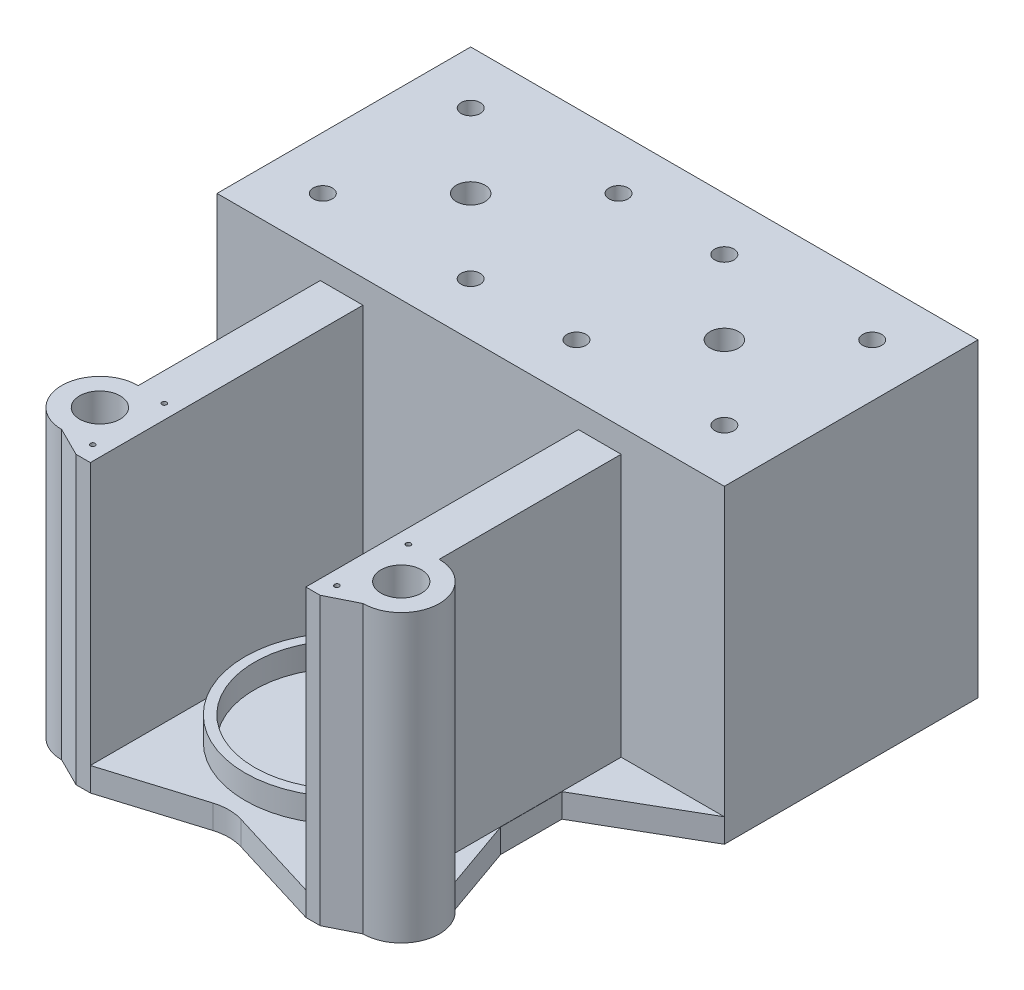
from build123d import *

# Parameters (mm, degrees)
SKETCH1_R                       = 21.15
BOSS_EXTRUDE1_DEPTH             = 5
SKETCH2_R                       = 21.15
SKETCH2_R_2                     = 19.15
BOSS_EXTRUDE2_DEPTH             = 10
SKETCH3_R                       = 8
SKETCH3_W                       = 53.18
SKETCH3_H                       = 53.18
SKETCH3_W_2                     = 43.18
SKETCH3_H_2                     = 43.18
SKETCH3_R_2                     = 21.15
BOSS_EXTRUDE4_DEPTH             = 5
SKETCH4_W                       = 106.36
SKETCH4_H                       = 53.18
SKETCH4_W_2                     = 43.18
SKETCH4_H_2                     = 43.18
SKETCH4_R                       = 0.5
SKETCH4_R_2                     = 4.25
BOSS_EXTRUDE5_DEPTH             = 55
BOSS_EXTRUDE5_DIRECTION_2_REACH = 97.637
SKETCH5_R                       = 1.566567696
SKETCH5_R_2                     = 1.356312868
SKETCH5_R_3                     = 1.387107712
SKETCH5_R_4                     = 1.945059914
BOSS_EXTRUDE6_DEPTH             = 50
SKETCH6_W                       = 106.36
SKETCH6_H                       = 53.18
SKETCH6_R                       = 3
SKETCH6_R_2                     = 2
BOSS_EXTRUDE7_DEPTH             = 5
SKETCH7_W                       = 22
SKETCH7_H                       = 23
CUT_EXTRUDE1_DEPTH              = 5
BOSS_EXTRUDE8_DEPTH             = 60
BOSS_EXTRUDE9_DEPTH             = 5


with BuildPart() as part:
    # Sketch1 → Boss-Extrude1 (new body)
    with BuildSketch(Plane(origin=(0, 0, 0), x_dir=(1, 0, 0), z_dir=(0, 1, 0))):
        with Locations(Location((0, 0, 0), (0, 0, 270))):
            Circle(SKETCH1_R)
    extrude(amount=BOSS_EXTRUDE1_DEPTH)

    # Sketch2 → Boss-Extrude2 (add)
    with BuildSketch(Plane(origin=(0, 0, 0), x_dir=(1, 0, 0), z_dir=(0, 1, 0))):
        with Locations(Location((0, 0, 0), (0, 0, 270))):
            Circle(SKETCH2_R)
        with Locations(Location((0, 0, 0), (0, 0, 270))):
            Circle(SKETCH2_R_2, mode=Mode.SUBTRACT)
    extrude(amount=BOSS_EXTRUDE2_DEPTH)

    # Sketch3 → Boss-Extrude4 (add)
    with BuildSketch(Plane(origin=(0, 0, 0), x_dir=(1, 0, 0), z_dir=(0, 1, 0))):
        with Locations((31.59, -20)):
            Circle(SKETCH3_R)
        with Locations((-31.59, -20)):
            Circle(SKETCH3_R)
        with Locations((26.59, 52.74)):
            Rectangle(SKETCH3_W, SKETCH3_H)
        with Locations((26.59, 52.74)):
            Rectangle(SKETCH3_W_2, SKETCH3_H_2, mode=Mode.SUBTRACT)
        with Locations((-26.59, 52.74)):
            Rectangle(SKETCH3_W, SKETCH3_H)
        with Locations((-26.59, 52.74)):
            Rectangle(SKETCH3_W_2, SKETCH3_H_2, mode=Mode.SUBTRACT)
        with BuildLine():
            Line((53.18, 26.15), (0, 26.15))
            Line((0, 26.15), (-53.18, 26.15))
            Line((-53.18, 26.15), (-31.59, 13.685007688))
            Line((-31.59, 13.685007688), (-31.59, 0.832649627))
            Line((-31.59, 0.832649627), (-36.793594364, -13.923602573))
            ThreePointArc((-36.793594364, -13.923602573), (-28.245508627, -12.732649901), (-23.59, -20))
            ThreePointArc((-23.59, -20), (-24.322649901, -23.344491373), (-26.386405636, -26.076397427))
            Line((-26.386405636, -26.076397427), (0, -21.15))
            Line((0, -21.15), (26.386405636, -26.076397427))
            ThreePointArc((26.386405636, -26.076397427), (25.513602573, -14.796405636), (36.793594364, -13.923602573))
            Line((36.793594364, -13.923602573), (31.59, 0.832649627))
            Line((31.59, 0.832649627), (31.59, 13.685007688))
            Line((31.59, 13.685007688), (53.18, 26.15))
        make_face()
        with BuildLine():
            ThreePointArc((21.15, 0), (14.955308422, -14.955308422), (0, -21.15))
            ThreePointArc((0, -21.15), (-14.955308422, 14.955308422), (21.15, 0))
        make_face(mode=Mode.SUBTRACT)
        with Locations(Location((0, 0, 0), (0, 0, 270))):
            Circle(SKETCH3_R_2)
    extrude(amount=BOSS_EXTRUDE4_DEPTH)

    # Sketch4 → Boss-Extrude5 (add)
    with BuildSketch(Plane(origin=(0, 5, 0), x_dir=(1, 0, 0), z_dir=(0, 1, 0))):
        with Locations((0, 52.74)):
            Rectangle(SKETCH4_W, SKETCH4_H)
        with Locations((-26.59, 52.74)):
            Rectangle(SKETCH4_W_2, SKETCH4_H_2, mode=Mode.SUBTRACT)
        with Locations((26.59, 52.74)):
            Rectangle(SKETCH4_W_2, SKETCH4_H_2, mode=Mode.SUBTRACT)
        with BuildLine():
            ThreePointArc((-31.59, -12), (-39.59, -20), (-31.59, -28))
            Line((-31.59, -28), (-25.59, -31))
            Line((-25.59, -31), (-22.59, -31))
            Line((-22.59, -31), (-22.59, -9))
            Line((-22.59, -9), (-25.59, -9))
            Line((-25.59, -9), (-31.59, -12))
        make_face()
        with Locations(Location((-25.59, -27.5, 0), (0, 0, 270))):
            Circle(SKETCH4_R, mode=Mode.SUBTRACT)
        with Locations(Location((-31.59, -20, 0), (0, 0, 270))):
            Circle(SKETCH4_R_2, mode=Mode.SUBTRACT)
        with Locations(Location((-25.59, -12.5, 0), (0, 0, 270))):
            Circle(SKETCH4_R, mode=Mode.SUBTRACT)
        with BuildLine():
            Line((31.59, -12), (25.59, -9))
            Line((25.59, -9), (22.59, -9))
            Line((22.59, -9), (22.59, -31))
            Line((22.59, -31), (25.59, -31))
            Line((25.59, -31), (31.59, -28))
            ThreePointArc((31.59, -28), (39.59, -20), (31.59, -12))
        make_face()
        with Locations(Location((25.59, -27.5, 0), (0, 0, 270))):
            Circle(SKETCH4_R, mode=Mode.SUBTRACT)
        with Locations(Location((25.59, -12.5, 0), (0, 0, 270))):
            Circle(SKETCH4_R, mode=Mode.SUBTRACT)
        with Locations(Location((31.59, -20, 0), (0, 0, 270))):
            Circle(SKETCH4_R_2, mode=Mode.SUBTRACT)
    extrude(amount=BOSS_EXTRUDE5_DEPTH)

    # Boss-Extrude5 direction 2: up to this face of the body (flat: up to its plane)
    boss_extrude5_direction_2_end = Plane(part.part.faces().sort_by_distance((0, 0, -18.773899986))[0])
    # Sketch4 → Boss-Extrude5 direction 2 (add, up to the picked face)
    with BuildSketch(Plane(origin=(0, 5, 0), x_dir=(1, 0, 0), z_dir=(0, 1, 0)), mode=Mode.PRIVATE) as boss_extrude5_direction_2_sk1:
        with Locations((0, 52.74)):
            Rectangle(SKETCH4_W, SKETCH4_H)
        with Locations((-26.59, 52.74)):
            Rectangle(SKETCH4_W_2, SKETCH4_H_2, mode=Mode.SUBTRACT)
        with Locations((26.59, 52.74)):
            Rectangle(SKETCH4_W_2, SKETCH4_H_2, mode=Mode.SUBTRACT)
    boss_extrude5_direction_2_tool1 = split(extrude(boss_extrude5_direction_2_sk1.sketch, amount=-BOSS_EXTRUDE5_DIRECTION_2_REACH, mode=Mode.PRIVATE), bisect_by=boss_extrude5_direction_2_end, keep=Keep.BOTH, mode=Mode.PRIVATE)
    # Sketch4 → Boss-Extrude5 direction 2 (add, up to the picked face)
    with BuildSketch(Plane(origin=(0, 5, 0), x_dir=(1, 0, 0), z_dir=(0, 1, 0)), mode=Mode.PRIVATE) as boss_extrude5_direction_2_sk2:
        with BuildLine():
            ThreePointArc((-31.59, -12), (-39.59, -20), (-31.59, -28))
            Line((-31.59, -28), (-25.59, -31))
            Line((-25.59, -31), (-22.59, -31))
            Line((-22.59, -31), (-22.59, -9))
            Line((-22.59, -9), (-25.59, -9))
            Line((-25.59, -9), (-31.59, -12))
        make_face()
        with Locations(Location((-25.59, -27.5, 0), (0, 0, 270))):
            Circle(SKETCH4_R, mode=Mode.SUBTRACT)
        with Locations(Location((-31.59, -20, 0), (0, 0, 270))):
            Circle(SKETCH4_R_2, mode=Mode.SUBTRACT)
        with Locations(Location((-25.59, -12.5, 0), (0, 0, 270))):
            Circle(SKETCH4_R, mode=Mode.SUBTRACT)
    boss_extrude5_direction_2_tool2 = split(extrude(boss_extrude5_direction_2_sk2.sketch, amount=-BOSS_EXTRUDE5_DIRECTION_2_REACH, mode=Mode.PRIVATE), bisect_by=boss_extrude5_direction_2_end, keep=Keep.BOTH, mode=Mode.PRIVATE)
    # Sketch4 → Boss-Extrude5 direction 2 (add, up to the picked face)
    with BuildSketch(Plane(origin=(0, 5, 0), x_dir=(1, 0, 0), z_dir=(0, 1, 0)), mode=Mode.PRIVATE) as boss_extrude5_direction_2_sk3:
        with BuildLine():
            Line((31.59, -12), (25.59, -9))
            Line((25.59, -9), (22.59, -9))
            Line((22.59, -9), (22.59, -31))
            Line((22.59, -31), (25.59, -31))
            Line((25.59, -31), (31.59, -28))
            ThreePointArc((31.59, -28), (39.59, -20), (31.59, -12))
        make_face()
        with Locations(Location((25.59, -27.5, 0), (0, 0, 270))):
            Circle(SKETCH4_R, mode=Mode.SUBTRACT)
        with Locations(Location((25.59, -12.5, 0), (0, 0, 270))):
            Circle(SKETCH4_R, mode=Mode.SUBTRACT)
        with Locations(Location((31.59, -20, 0), (0, 0, 270))):
            Circle(SKETCH4_R_2, mode=Mode.SUBTRACT)
    boss_extrude5_direction_2_tool3 = split(extrude(boss_extrude5_direction_2_sk3.sketch, amount=-BOSS_EXTRUDE5_DIRECTION_2_REACH, mode=Mode.PRIVATE), bisect_by=boss_extrude5_direction_2_end, keep=Keep.BOTH, mode=Mode.PRIVATE)
    add(boss_extrude5_direction_2_tool1.solids().sort_by(Axis((0, 5, -52.74), (0, -1, 0)))[0])
    add(boss_extrude5_direction_2_tool2.solids().sort_by(Axis((-39.311971, 5, 20), (0, -1, 0)))[0])
    add(boss_extrude5_direction_2_tool3.solids().sort_by(Axis((28.465662, 5, 10.748676), (0, -1, 0)))[0])

    # Sketch5 → Boss-Extrude6 (add)
    with BuildSketch(Plane(origin=(0, 5, 0), x_dir=(1, 0, 0), z_dir=(0, 1, 0))):
        with Locations((-25.59, -27.5)):
            Circle(SKETCH5_R)
        with Locations((-25.59, -12.5)):
            Circle(SKETCH5_R_2)
        with Locations((25.59, -12.5)):
            Circle(SKETCH5_R_3)
        with Locations((25.59, -23.409830044)):
            Circle(SKETCH5_R_4)
    extrude(amount=BOSS_EXTRUDE6_DEPTH)

    # Sketch6 → Boss-Extrude7 (add)
    with BuildSketch(Plane(origin=(0, 60, 0), x_dir=(1, 0, 0), z_dir=(0, 1, 0))):
        with Locations((0, 52.74)):
            Rectangle(SKETCH6_W, SKETCH6_H)
        with Locations(Location((-26.59, 52.74, 0), (0, 0, 270))):
            Circle(SKETCH6_R, mode=Mode.SUBTRACT)
        with Locations(Location((26.59, 52.74, 0), (0, 0, 270))):
            Circle(SKETCH6_R, mode=Mode.SUBTRACT)
        with Locations(Location((-42.09, 68.24, 0), (0, 0, 270))):
            Circle(SKETCH6_R_2, mode=Mode.SUBTRACT)
        with Locations(Location((-11.09, 68.24, 0), (0, 0, 270))):
            Circle(SKETCH6_R_2, mode=Mode.SUBTRACT)
        with Locations(Location((-11.09, 37.24, 0), (0, 0, 270))):
            Circle(SKETCH6_R_2, mode=Mode.SUBTRACT)
        with Locations(Location((-42.09, 37.24, 0), (0, 0, 270))):
            Circle(SKETCH6_R_2, mode=Mode.SUBTRACT)
        with Locations(Location((11.09, 68.24, 0), (0, 0, 90))):
            Circle(SKETCH6_R_2, mode=Mode.SUBTRACT)
        with Locations(Location((11.09, 37.24, 0), (0, 0, 90))):
            Circle(SKETCH6_R_2, mode=Mode.SUBTRACT)
        with Locations(Location((42.09, 37.24, 0), (0, 0, 90))):
            Circle(SKETCH6_R_2, mode=Mode.SUBTRACT)
        with Locations(Location((42.09, 68.24, 0), (0, 0, 90))):
            Circle(SKETCH6_R_2, mode=Mode.SUBTRACT)
    extrude(amount=BOSS_EXTRUDE7_DEPTH)

    # Sketch7 → Cut-Extrude1 (cut)
    with BuildSketch(Plane(origin=(0, 0, -79.33), x_dir=(-1, 0, 0), z_dir=(0, 0, -1))):
        with Locations((-28.18, 11.5)):
            Rectangle(SKETCH7_W, SKETCH7_H)
        with Locations((28.18, 11.5)):
            Rectangle(SKETCH7_W, SKETCH7_H)
    extrude(amount=-CUT_EXTRUDE1_DEPTH, mode=Mode.SUBTRACT)

    # Sketch8 → Boss-Extrude8 (add)
    with BuildSketch(Plane(origin=(0, 60, 0), x_dir=(1, 0, 0), z_dir=(0, 1, 0))):
        Polygon((-31.542803854, -13.152023689), (-31.542803854, 26.15), (-22.59, 26.15), (-22.59, -9.877338884), (-22.59, -11.171477367), align=None)
        Polygon((31.542803854, 26.15), (22.59, 26.15), (22.59, -9.877338884), (22.59, -11.171477367), (31.542803854, -13.152023689), align=None)
    extrude(amount=-BOSS_EXTRUDE8_DEPTH)

    # Sketch9 → Boss-Extrude9 (add)
    with BuildSketch(Plane(origin=(0, 5, 0), x_dir=(1, 0, 0), z_dir=(0, 1, 0))):
        with BuildLine():
            Line((-22.59, -25.36760051), (-22.59, -31))
            Line((-22.59, -31), (-2.93570785, -24.964116951))
            ThreePointArc((-2.93570785, -24.964116951), (0, -24.523490331), (2.93570785, -24.964116951))
            Line((2.93570785, -24.964116951), (22.59, -31))
            Line((22.59, -31), (22.59, -25.36760051))
            Line((22.59, -25.36760051), (0, -21.15))
            Line((0, -21.15), (-22.59, -25.36760051))
        make_face()
    extrude(amount=-BOSS_EXTRUDE9_DEPTH)


solid = part.part
